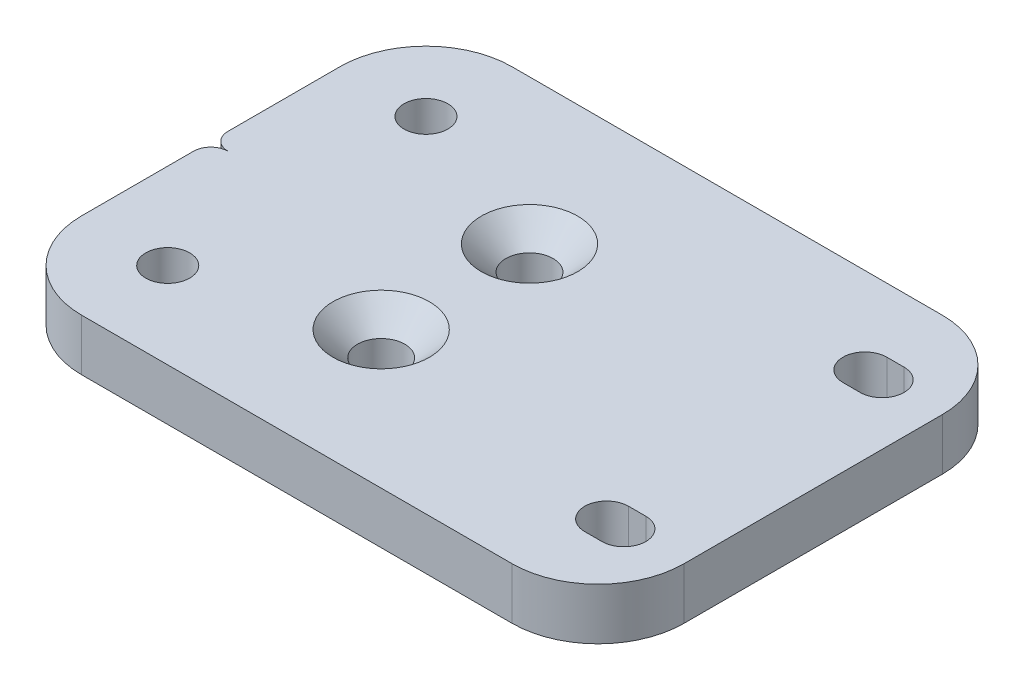
from build123d import *

# Parameters (mm, degrees)
EXTRUDE_1_DEPTH             = 6
SKETCH_2_R                  = 2.55
CUT_EXTRUDE_1_DEPTH         = 7
CUT_EXTRUDE_2_DEPTH         = 7
HOLE_WIZARD_M52_D           = 5.5
HOLE_WIZARD_M52_CSINK_D     = 11.2
HOLE_WIZARD_M52_CSINK_ANGLE = 90


with BuildPart() as part:
    # Эскиз1 → Бобышка-Вытянуть1 (new body)
    with BuildSketch(Plane(origin=(0, 0, 0), x_dir=(1, 0, 0), z_dir=(0, 1, 0))):
        with BuildLine():
            Line((-25, -25), (25, -25))
            ThreePointArc((25, -25), (32.071067812, -22.071067812), (35, -15))
            Line((35, -15), (35, 15))
            ThreePointArc((35, 15), (32.071067812, 22.071067812), (25, 25))
            Line((25, 25), (-25, 25))
            ThreePointArc((-25, 25), (-32.071067812, 22.071067812), (-35, 15))
            Line((-35, 15), (-35, -15))
            ThreePointArc((-35, -15), (-32.071067812, -22.071067812), (-25, -25))
        make_face()
    extrude(amount=EXTRUDE_1_DEPTH)

    # Эскиз2 → Вырез-Вытянуть1 (cut, through all)
    with BuildSketch(Plane.XZ):
        with Locations((-25, -15)):
            Circle(SKETCH_2_R)
        with Locations((-25, 15)):
            Circle(SKETCH_2_R)
        with BuildLine():
            Line((28, -17.55), (26, -17.55))
            ThreePointArc((26, -17.55), (23.45, -15), (26, -12.45))
            Line((26, -12.45), (28, -12.45))
            ThreePointArc((28, -12.45), (30.55, -15), (28, -17.55))
        make_face()
        with BuildLine():
            Line((28, 17.55), (26, 17.55))
            ThreePointArc((26, 17.55), (23.45, 15), (26, 12.45))
            Line((26, 12.45), (28, 12.45))
            ThreePointArc((28, 12.45), (30.55, 15), (28, 17.55))
        make_face()
    extrude(amount=-CUT_EXTRUDE_1_DEPTH, mode=Mode.SUBTRACT)

    # Эскиз3 → Вырез-Вытянуть2 (cut, through all)
    with BuildSketch(Plane.XZ):
        with BuildLine():
            Line((-35, -2), (-35, 2))
            ThreePointArc((-35, 2), (-34.414213562, 0.585786438), (-33, 0))
            ThreePointArc((-33, 0), (-34.414213562, -0.585786438), (-35, -2))
        make_face()
    extrude(amount=-CUT_EXTRUDE_2_DEPTH, mode=Mode.SUBTRACT)

    # Зенковка для  винта с потайной головкой с внутренним шестигранником M52 (through all)
    with Locations(Plane(origin=(0, 6, 0), x_dir=(1, 0, 0), z_dir=(0, 1, 0))):
        with Locations((-6.159381211, -9.040339254), (-6.159381211, 8.192585184)):
            CounterSinkHole(HOLE_WIZARD_M52_D / 2, HOLE_WIZARD_M52_CSINK_D / 2, counter_sink_angle=HOLE_WIZARD_M52_CSINK_ANGLE)


solid = part.part
